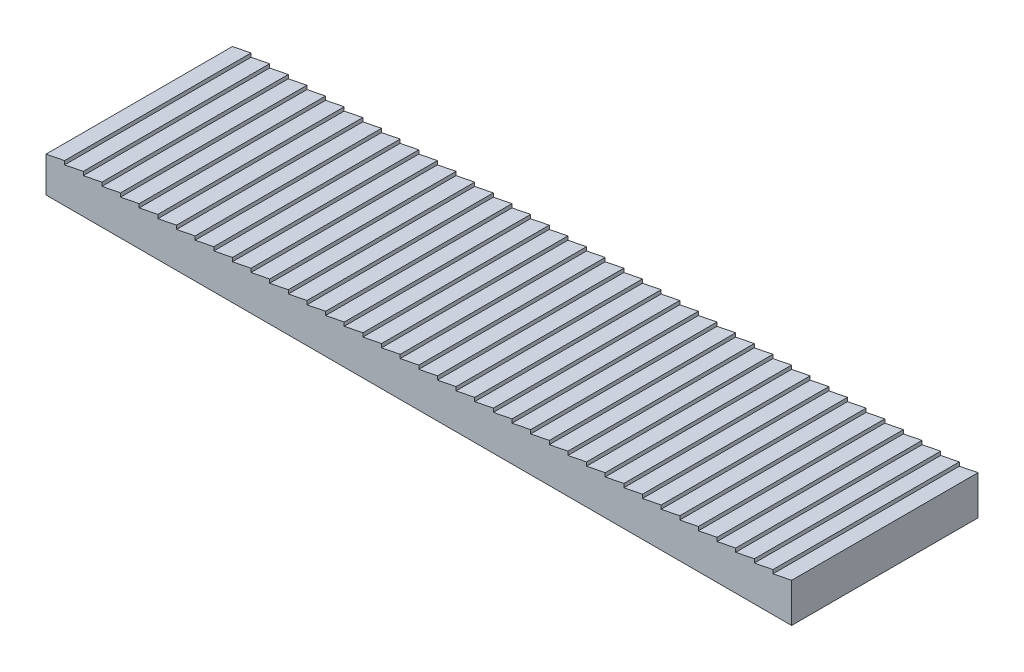
from build123d import *

# Parameters (mm, degrees)
AUFSATZ_LINEAR_AUSTRAGEN1_DEPTH = 50


with BuildPart() as part:
    # Skizze1 → Aufsatz-Linear austragen1 (new body)
    with BuildSketch(Plane.XY):
        Polygon((200, -9.5), (0, -9.5), (0, 0), (5, 1), (5, 0), (10, 1), (10, 0), (15, 1), (15, 0), (20, 1), (20, 0), (25, 1), (25, 0), (30, 1), (30, 0), (35, 1), (35, 0), (40, 1), (40, 0), (45, 1), (45, 0), (50, 1), (50, 0), (55, 1), (55, 0), (60, 1), (60, 0), (65, 1), (65, 0), (70, 1), (70, 0), (75, 1), (75, 0), (80, 1), (80, 0), (85, 1), (85, 0), (90, 1), (90, 0), (95, 1), (95, 0), (100, 1), (100, 0), (105, 1), (105, 0), (110, 1), (110, 0), (115, 1), (115, 0), (120, 1), (120, 0), (125, 1), (125, 0), (130, 1), (130, 0), (135, 1), (135, 0), (140, 1), (140, 0), (145, 1), (145, 0), (150, 1), (150, 0), (155, 1), (155, 0), (160, 1), (160, 0), (165, 1), (165, 0), (170, 1), (170, 0), (175, 1), (175, 0), (180, 1), (180, 0), (185, 1), (185, 0), (190, 1), (190, 0), (195, 1), (195, 0), (200, 1), (200, 0), align=None)
    extrude(amount=AUFSATZ_LINEAR_AUSTRAGEN1_DEPTH)


solid = part.part
